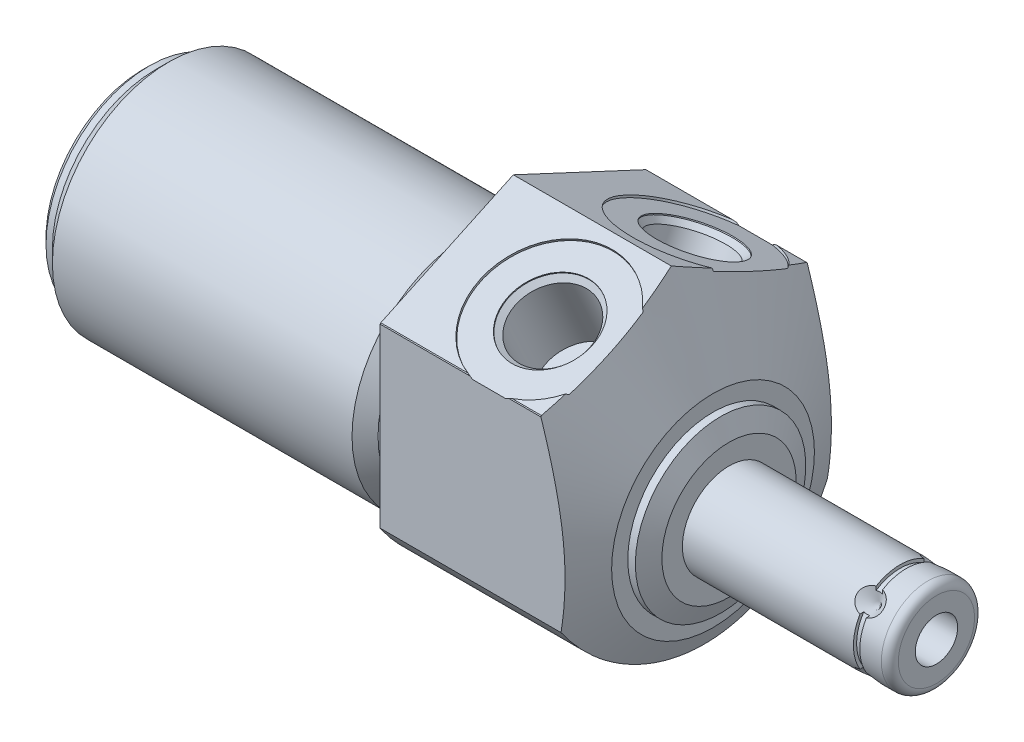
from build123d import *

# Parameters (mm, degrees)
SKETCH1_R           = 25.4
EXTRUDE1_DEPTH      = 25.7048
EXTRUDE1_DEPTH_BACK = 44.1452
CUT_EXTRUDE1_REACH  = 46.145
SKETCH2_R           = 25.4
SKETCH2_R_2         = 13.8684
CUT_EXTRUDE3_REACH  = 71.85
SKETCH4_R           = 25.4
CHAMFER1_SIZE       = 0.762
CIRPATTERN1_COUNT   = 4
SKETCH21_W          = 0.762
SKETCH21_H          = 0.381


with BuildPart() as part:
    # Sketch1 → Extrude1 (new body, two sides)
    with BuildSketch(Plane(origin=(0, 0, 0), x_dir=(0, 0, -1), z_dir=(1, 0, 0))) as extrude1_sk:
        Circle(SKETCH1_R)
    extrude(amount=EXTRUDE1_DEPTH)
    extrude(extrude1_sk.sketch, amount=-EXTRUDE1_DEPTH_BACK)

    # Sketch2 → Cut-Extrude1 (cut, up to next)
    with BuildSketch(Plane(origin=(0, 0, 0), x_dir=(0, 0, -1), z_dir=(1, 0, 0)), mode=Mode.PRIVATE) as cut_extrude1_sk1:
        Circle(SKETCH2_R)
        with Locations((0, -4.7498)):
            Circle(SKETCH2_R_2, mode=Mode.SUBTRACT)
    cut_extrude1_tool1 = extrude(cut_extrude1_sk1.sketch, amount=-CUT_EXTRUDE1_REACH, mode=Mode.PRIVATE) & part.part
    add(cut_extrude1_tool1.solids().sort_by_distance((0, 0, 24.68158))[0], mode=Mode.SUBTRACT)

    # Sketch4 → Cut-Extrude3 (cut, up to next)
    with BuildSketch(Plane.ZY.offset(-25.7048), mode=Mode.PRIVATE) as cut_extrude3_sk1:
        Circle(SKETCH4_R)
        with BuildLine():
            Line((15.875, -10.530283709), (15.875, 10.530283709))
            ThreePointArc((15.875, 10.530283709), (15.839063031, 10.584261065), (15.802942532, 10.638115779))
            Line((15.802942532, 10.638115779), (0, 18.007148903))
            Line((0, 18.007148903), (-15.802942532, 10.638115779))
            ThreePointArc((-15.802942532, 10.638115779), (-15.839063031, 10.584261065), (-15.875, 10.530283709))
            Line((-15.875, 10.530283709), (-15.875, -10.530283709))
            ThreePointArc((-15.875, -10.530283709), (0, -19.05), (15.875, -10.530283709))
        make_face(mode=Mode.SUBTRACT)
    cut_extrude3_tool1 = extrude(cut_extrude3_sk1.sketch, amount=CUT_EXTRUDE3_REACH, mode=Mode.PRIVATE) & part.part
    add(cut_extrude3_tool1.solids().sort_by_distance((25.7048, 0, -24.68158))[0], mode=Mode.SUBTRACT)

    # Sketch6 → Cut-Revolve2 (revolve, cut)
    with BuildSketch(Plane.XY, mode=Mode.PRIVATE) as cut_revolve2_sk:
        Polygon((18.823988023, 18.007148903), (23.7998, 7.336485684), (23.7998, 5.4102), (24.698041766, 5.4102), (25.7048, 3.2512), (25.7048, 18.007148903), align=None)
    revolve(cut_revolve2_sk.sketch.rotate(Axis((1.987224567, -4.7498, 0), (1, 0, 0)), 90), axis=Axis((1.987224567, -4.7498, 0), (1, 0, 0)), mode=Mode.SUBTRACT)  # turned: the seam where the file's is

    # S2D0002 → Cut-Revolve3 (revolve, cut)
    with BuildSketch(Plane(origin=(13.0048, 13.712414668, 8.609072086), x_dir=(0, 0.422618262, -0.906307787), z_dir=(1, 0, 0))):
        Polygon((5.0165, 0), (8.255, 0), (8.255, 0.254), (0, 0.254), (0, -9.398), (4.4196, -9.398), (4.4196, -0.7239), (5.0165, -0.127), align=None)
    cut_revolve3 = revolve(axis=Axis((13.0048, 2.110224902, 3.198882147), (0, 0.906307787, 0.422618262)), mode=Mode.SUBTRACT)

    # Mirror1: Cut-Revolve3 across plane
    add(cut_revolve3.mirror(Plane.XY), mode=Mode.SUBTRACT)

    # Sketch10 → Cut-Revolve6 (revolve, cut)
    with BuildSketch(Plane.XY, mode=Mode.PRIVATE) as cut_revolve6_sk:
        Polygon((0, 9.1186), (0, 7.5692), (-3.81, 7.5692), (-5.3594, 9.1186), align=None)
    revolve(cut_revolve6_sk.sketch.rotate(Axis((-5.09397, -4.7498, 0), (1, 0, 0)), 90), axis=Axis((-5.09397, -4.7498, 0), (1, 0, 0)), mode=Mode.SUBTRACT)  # turned: the seam where the file's is

    # Sketch12 → Cut-Revolve8 (revolve, cut)
    with BuildSketch(Plane.XY, mode=Mode.PRIVATE) as cut_revolve8_sk:
        Polygon((-44.1452, 9.1186), (-44.1452, 7.5692), (-42.6212, 7.5692), (-41.0718, 9.1186), align=None)
    revolve(cut_revolve8_sk.sketch.rotate(Axis((-50.92827, -4.7498, 0), (1, 0, 0)), 90), axis=Axis((-50.92827, -4.7498, 0), (1, 0, 0)), mode=Mode.SUBTRACT)  # turned: the seam where the file's is

    # Chamfer1
    chamfer1_edges = [part.edges().sort_by_distance(p)[0] for p in [
        (-44.1452, -4.7498, -12.319),
    ]]
    chamfer(chamfer1_edges, length=CHAMFER1_SIZE)

    # Sketch13 → Revolve1 (revolve)
    with BuildSketch(Plane.XY, mode=Mode.PRIVATE) as revolve1_sk:
        with BuildLine():
            Line((25.7048, -4.7498), (50.432, -4.7498))
            Line((50.432, -4.7498), (50.432, -9.29005))
            ThreePointArc((50.432, -9.29005), (50.13442049, -10.00847049), (49.416, -10.30605))
            Line((49.416, -10.30605), (25.7048, -10.30605))
            Line((25.7048, -10.30605), (25.7048, -4.7498))
        make_face()
    revolve(revolve1_sk.sketch.rotate(Axis((4.7498, -4.7498, 0), (1, 0, 0)), 270), axis=Axis((4.7498, -4.7498, 0), (1, 0, 0)))  # turned: the seam where the file's is

    # S2D0001 → Cut-Revolve9 (revolve, cut)
    with BuildSketch(Plane.XY, mode=Mode.PRIVATE) as cut_revolve9_sk:
        Polygon((50.432, -2.2225), (40.272, -2.2225), (38.753444958, -4.7498), (50.432, -4.7498), align=None)
    revolve(cut_revolve9_sk.sketch.rotate(Axis((-2.8067, -4.7498, 0), (-1, 0, 0)), 270), axis=Axis((-2.8067, -4.7498, 0), (-1, 0, 0)), mode=Mode.SUBTRACT)  # turned: the seam where the file's is

    # Sketch16 → Cut-Revolve10 (revolve, cut)
    with BuildSketch(Plane(origin=(0, -8.108415789, 3.358615789), x_dir=(1, 0, 0), z_dir=(0, -0.707106781, -0.707106781)), mode=Mode.PRIVATE) as cut_revolve10_sk:
        Polygon((46.4696, -10.30605), (44.8821, -10.30605), (46.4696, -8.71855), align=None)
    cut_revolve10 = revolve(cut_revolve10_sk.sketch.rotate(Axis((46.4696, -5.648535273, 0.898735273), (0, -0.707106781, 0.707106781)), 270), axis=Axis((46.4696, -5.648535273, 0.898735273), (0, -0.707106781, 0.707106781)), mode=Mode.SUBTRACT)  # turned: the seam where the file's is

    # CirPattern1: Cut-Revolve10 ×4 about axis
    cirpattern1_axis = Axis((4.7498, -4.7498, 0), (-1, 0, 0))
    for i in range(1, CIRPATTERN1_COUNT):
        add(cut_revolve10.rotate(cirpattern1_axis, i * 360 / CIRPATTERN1_COUNT), mode=Mode.SUBTRACT)

    # Sketch21 → Cut-Revolve11 (revolve, cut)
    with BuildSketch(Plane.XY, mode=Mode.PRIVATE) as cut_revolve11_sk:
        with Locations((46.4696, 0.61595)):
            Rectangle(SKETCH21_W, SKETCH21_H)
    revolve(cut_revolve11_sk.sketch.rotate(Axis((23.873488058, -4.7498, 0), (1, 0, 0)), 90), axis=Axis((23.873488058, -4.7498, 0), (1, 0, 0)), mode=Mode.SUBTRACT)  # turned: the seam where the file's is


solid = part.part
